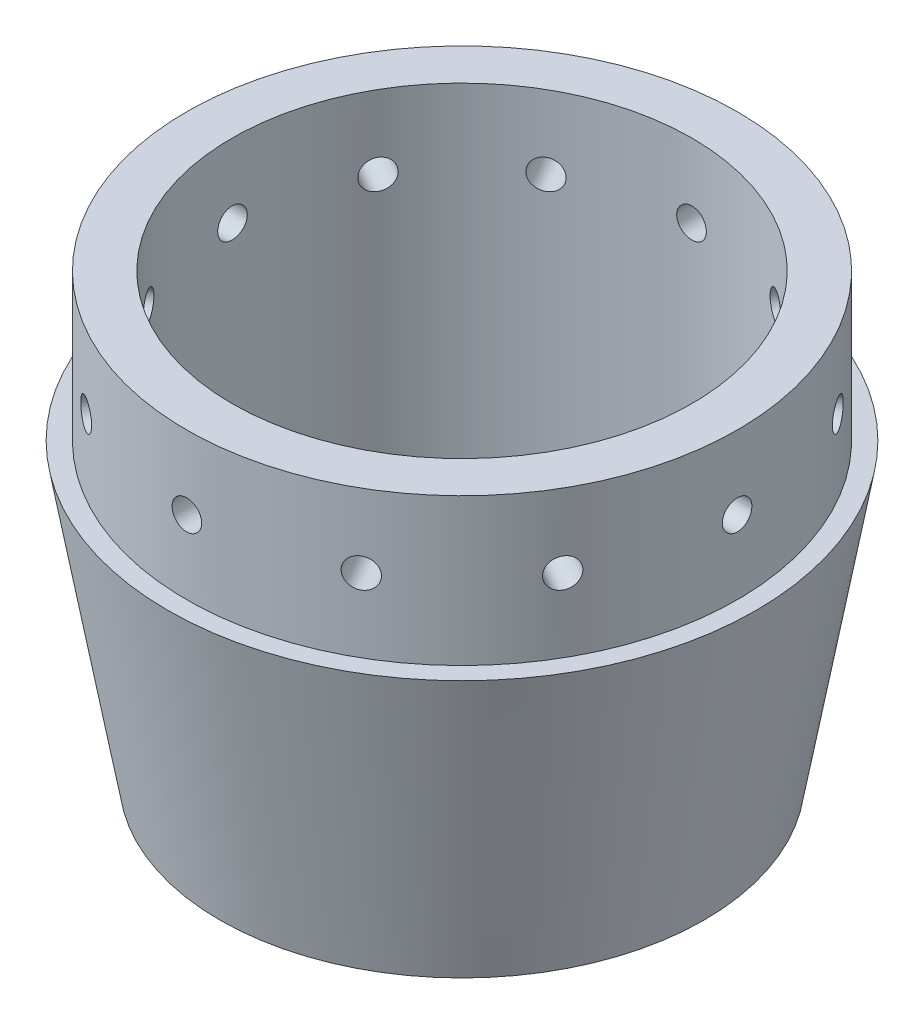
from build123d import *

# Parameters (mm, degrees)
TAP_DRILL_FOR_1_4_20_TAP1_REACH  = 136.414
TAP_DRILL_FOR_1_4_20_TAP1_BORE_R = 2.5527
CIRPATTERN1_COUNT                = 12


with BuildPart() as part:
    # Sketch1 → Revolve1 (revolve)
    with BuildSketch(Plane.XY, mode=Mode.PRIVATE) as revolve1_sk:
        Polygon((-39.7256, 0), (-41.84258938, 0), (-50.8, 50.8), (-47.5869, 50.8), (-47.5869, 76.2), (-39.7256, 76.2), align=None)
    revolve(revolve1_sk.sketch.rotate(Axis((0, 0, 0), (0, 1, 0)), 270), axis=Axis((0, 0, 0), (0, 1, 0)))

    # Tap Drill for 1/4-20 Tap1 bore → Tap Drill for 1/4-20 Tap1 (cut, up to next)
    with BuildSketch(Plane(origin=(0, 0, -47.5869), x_dir=(-1, 0, 0), z_dir=(0, 0, -1)), mode=Mode.PRIVATE) as tap_drill_for_1_4_20_tap1_sk1:
        with Locations((0, 63.5)):
            Circle(TAP_DRILL_FOR_1_4_20_TAP1_BORE_R)
    tap_drill_for_1_4_20_tap1_tool1 = extrude(tap_drill_for_1_4_20_tap1_sk1.sketch, amount=-TAP_DRILL_FOR_1_4_20_TAP1_REACH, mode=Mode.PRIVATE) & part.part
    tap_drill_for_1_4_20_tap1 = tap_drill_for_1_4_20_tap1_tool1.solids().sort_by_distance((0, 63.5, -47.5869))[0]
    add(tap_drill_for_1_4_20_tap1, mode=Mode.SUBTRACT)

    # CirPattern1: Tap Drill for 1/4-20 Tap1 ×12 about axis
    cirpattern1_axis = Axis((0, 0, 0), (0, -1, 0))
    for i in range(1, CIRPATTERN1_COUNT):
        add(tap_drill_for_1_4_20_tap1.rotate(cirpattern1_axis, i * 360 / CIRPATTERN1_COUNT), mode=Mode.SUBTRACT)


solid = part.part
